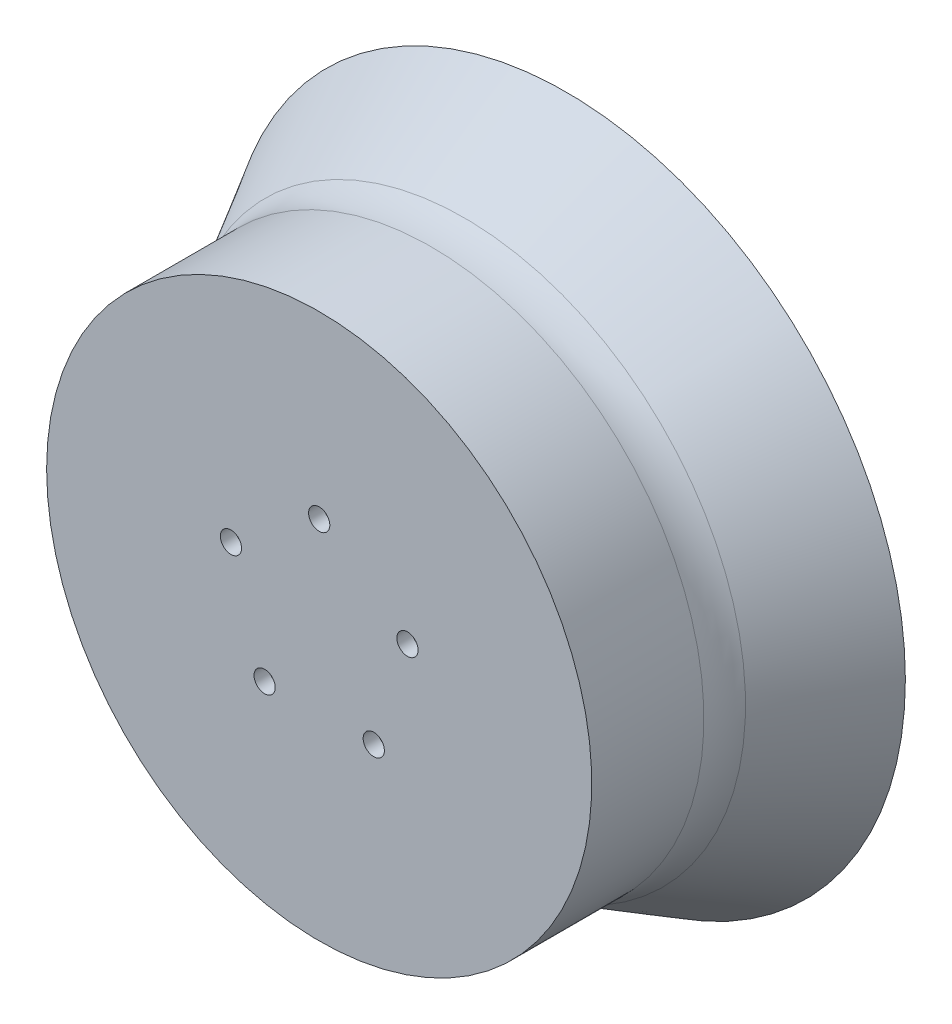
from build123d import *

# Parameters (mm, degrees)
SKETCH2_R          = 1.8288
CUT_EXTRUDE1_DEPTH = 43.573973945


with BuildPart() as part:
    # Sketch1 → Revolve1 (revolve)
    with BuildSketch(Plane(origin=(0, 0, 0), x_dir=(1, 0, 0), z_dir=(0, 1, 0))):
        with BuildLine():
            Line((7.9629, -25.4), (44.45, -25.4))
            Line((44.45, -25.4), (44.45, 0))
            Line((44.45, 0), (46.99, 0))
            Line((46.99, 0), (58.473357526, 14.633973945))
            Line((58.473357526, 14.633973945), (48.488896002, -2.93998396))
            ThreePointArc((48.488896002, -2.93998396), (47.371046022, -5.678922959), (46.99, -8.612551998))
            Line((46.99, -8.612551998), (46.99, -27.94))
            Line((46.99, -27.94), (0, -27.94))
            Line((0, -27.94), (0, -15.24))
            Line((0, -15.24), (5.4229, -15.24))
            Line((5.4229, -15.24), (7.9629, -17.78))
            Line((7.9629, -17.78), (7.9629, -25.4))
        make_face()
    revolve(axis=Axis((0, 0, 0), (0, 0, 1)))

    # Sketch2 → Cut-Extrude1 (cut, through all)
    with BuildSketch(Plane.XY.offset(27.94)):
        with Locations((0, 16)):
            Circle(SKETCH2_R)
        with Locations((15.216904261, 4.94427191)):
            Circle(SKETCH2_R)
        with Locations((9.404564037, -12.94427191)):
            Circle(SKETCH2_R)
        with Locations((-9.404564037, -12.94427191)):
            Circle(SKETCH2_R)
        with Locations((-15.216904261, 4.94427191)):
            Circle(SKETCH2_R)
    extrude(amount=-CUT_EXTRUDE1_DEPTH, mode=Mode.SUBTRACT)


solid = part.part
